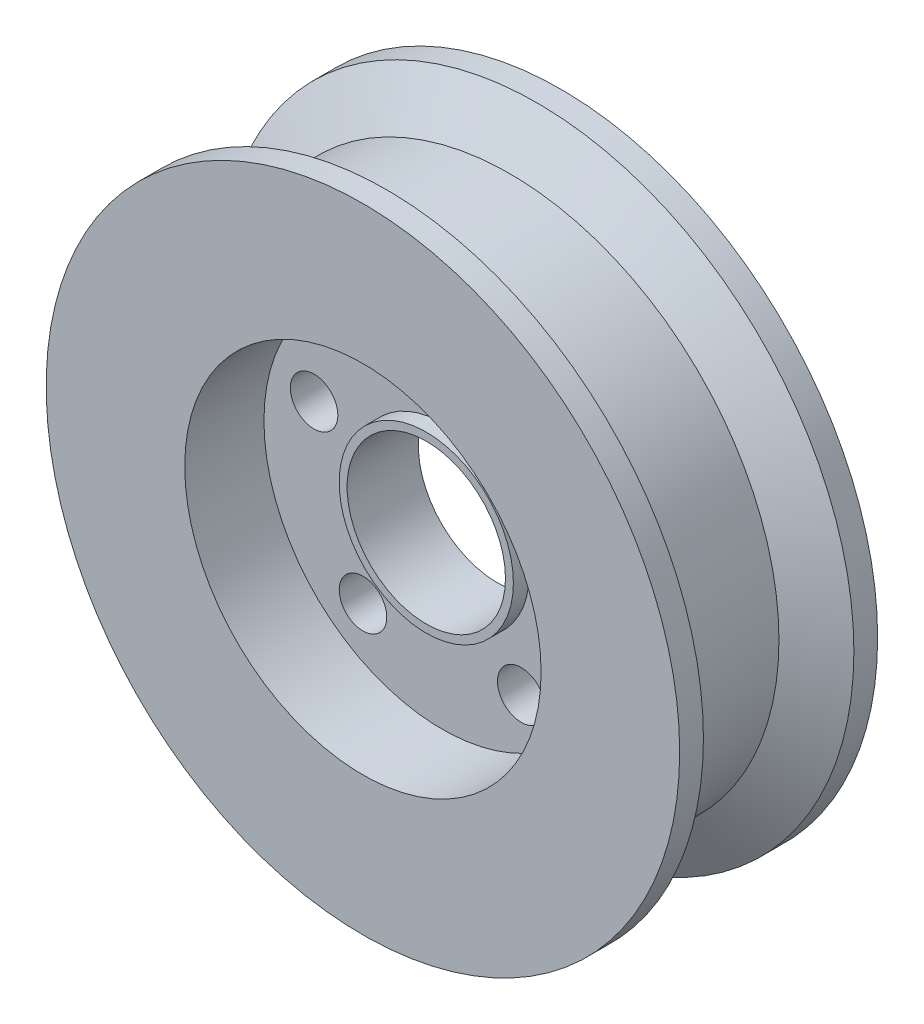
from build123d import *

# Parameters (mm, degrees)
SKETCH1_R                = 40
SKETCH1_R_2              = 10
BOSS_EXTRUDE1_DEPTH      = 12.5
SKETCH2_R                = 22.5
CUT_EXTRUDE1_DEPTH       = 10
SKETCH3_R                = 3
CUT_EXTRUDE2_DEPTH       = 16
CIRPATTERN1_COUNT        = 5
SKETCH5_R                = 11
SKETCH5_R_2              = 10
BOSS_EXTRUDE2_DEPTH      = 2
BOSS_EXTRUDE2_DEPTH_BACK = 7


with BuildPart() as part:
    # Sketch1 → Boss-Extrude1 (new body, symmetric)
    with BuildSketch(Plane.XY):
        Circle(SKETCH1_R)
        Circle(SKETCH1_R_2, mode=Mode.SUBTRACT)
    extrude(amount=BOSS_EXTRUDE1_DEPTH, both=True)

    # Sketch2 → Cut-Extrude1 (cut)
    with BuildSketch(Plane.XY.offset(12.5)):
        Circle(SKETCH2_R)
    cut_extrude1 = extrude(amount=-CUT_EXTRUDE1_DEPTH, mode=Mode.SUBTRACT)

    # Mirror1: Cut-Extrude1 across plane
    add(cut_extrude1.mirror(Plane.XY), mode=Mode.SUBTRACT)

    # Sketch3 → Cut-Extrude2 (cut, through all)
    with BuildSketch(Plane.XY.offset(2.5)):
        with Locations((0, 17)):
            Circle(SKETCH3_R)
    cut_extrude2 = extrude(amount=-CUT_EXTRUDE2_DEPTH, mode=Mode.SUBTRACT)

    # CirPattern1: Cut-Extrude2 ×5 about axis
    cirpattern1_axis = Axis((0, 0, 0), (0, 0, 1))
    for i in range(1, CIRPATTERN1_COUNT):
        add(cut_extrude2.rotate(cirpattern1_axis, i * 360 / CIRPATTERN1_COUNT), mode=Mode.SUBTRACT)

    # Sketch4 → Cut-Revolve1 (revolve, cut)
    with BuildSketch(Plane(origin=(0, 0, 0), x_dir=(1, 0, 0), z_dir=(0, 1, 0))):
        Polygon((40, 9.5), (40, -9.5), (34, -6.035898385), (34, 6.035898385), align=None)
    revolve(axis=Axis((0, 0, 0), (0, 0, -1)), mode=Mode.SUBTRACT)

    # Sketch5 → Boss-Extrude2 (add, two sides)
    with BuildSketch(Plane.XY.offset(2.5)) as boss_extrude2_sk:
        Circle(SKETCH5_R)
        Circle(SKETCH5_R_2, mode=Mode.SUBTRACT)
    extrude(amount=BOSS_EXTRUDE2_DEPTH)
    extrude(boss_extrude2_sk.sketch, amount=-BOSS_EXTRUDE2_DEPTH_BACK)


solid = part.part
